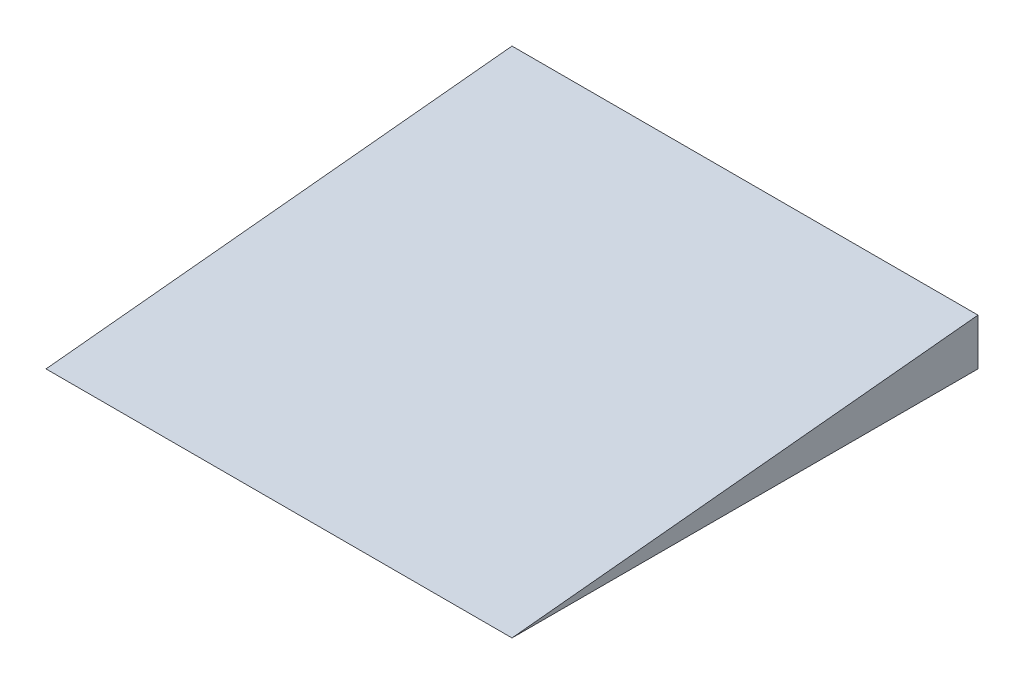
from build123d import *

# Parameters (mm, degrees)
SKETCH2_W           = 1000
SKETCH2_H           = 1000
BOSS_EXTRUDE1_DEPTH = 100
CUT_EXTRUDE1_DEPTH  = 1202


with BuildPart() as part:
    # Sketch2 → Boss-Extrude1 (new body)
    with BuildSketch(Plane(origin=(0, 0, 0), x_dir=(1, 0, 0), z_dir=(0, 1, 0))):
        with Locations((500, 500)):
            Rectangle(SKETCH2_W, SKETCH2_H)
    extrude(amount=BOSS_EXTRUDE1_DEPTH)

    # Sketch3 → Cut-Extrude1 (cut)
    with BuildSketch(Plane(origin=(1000, 0, 0), x_dir=(0, 0, -1), z_dir=(1, 0, 0))):
        Polygon((0, 0), (1000, 100), (0, 100), align=None)
    extrude(amount=-CUT_EXTRUDE1_DEPTH, mode=Mode.SUBTRACT)


solid = part.part
